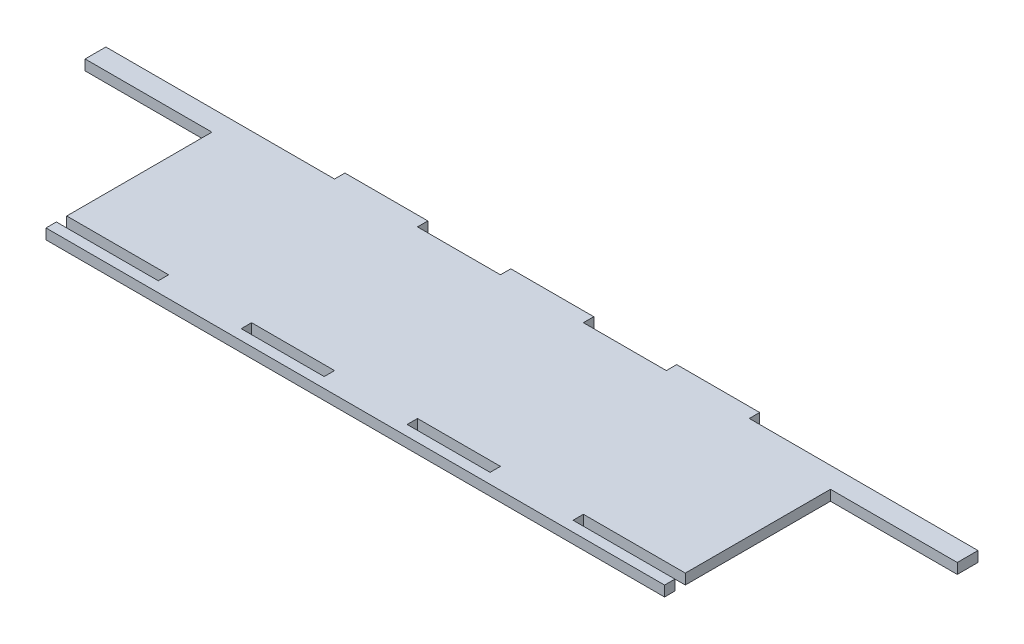
from build123d import *

# Parameters (mm, degrees)
SKETCH1_W           = 25.4
SKETCH1_H           = 3.175
BOSS_EXTRUDE1_DEPTH = 3.175


with BuildPart() as part:
    # Sketch1 → Boss-Extrude1 (new body)
    with BuildSketch(Plane(origin=(0, 0, 0), x_dir=(1, 0, 0), z_dir=(0, 1, 0))):
        Polygon((-133.525, 25.4), (-133.525, 19.05), (-94.7, 19.05), (-94.7, -25.4), (-63.5, -25.4), (-63.5, -28.575), (-94.7, -28.575), (-94.7, -31.75), (94.7, -31.75), (94.7, -28.575), (63.5, -28.575), (63.5, -25.4), (94.7, -25.4), (94.7, 19.05), (133.525, 19.05), (133.525, 25.4), (63.5, 25.4), (63.5, 28.575), (38.1, 28.575), (38.1, 25.4), (12.7, 25.4), (12.7, 28.575), (-12.7, 28.575), (-12.7, 25.4), (-38.1, 25.4), (-38.1, 28.575), (-63.5, 28.575), (-63.5, 25.4), align=None)
        with Locations((25.4, -26.9875)):
            Rectangle(SKETCH1_W, SKETCH1_H, mode=Mode.SUBTRACT)
        with Locations((-25.4, -26.9875)):
            Rectangle(SKETCH1_W, SKETCH1_H, mode=Mode.SUBTRACT)
    extrude(amount=BOSS_EXTRUDE1_DEPTH)


solid = part.part
